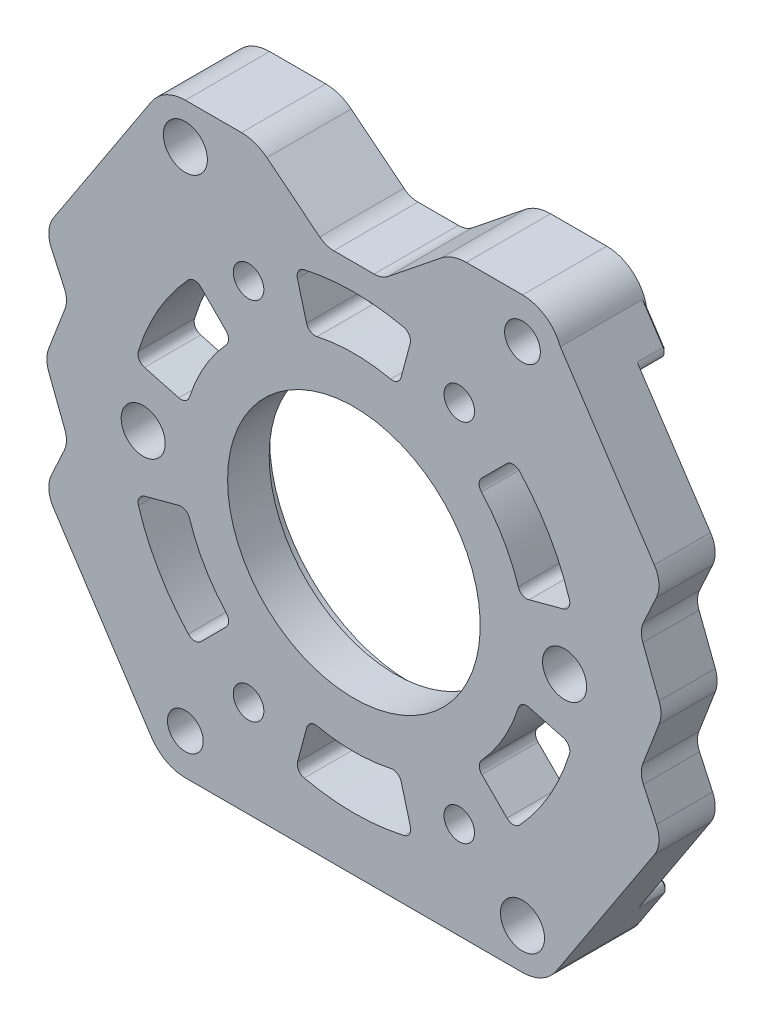
from build123d import *

# Parameters (mm, degrees)
BOSS_EXTRUDE1_DEPTH             = 6.3500000000000005
BOSS_EXTRUDE2_START             = 3.1750000000000025
BOSS_EXTRUDE2_DEPTH             = 3.1750000000000025
BOSS_EXTRUDE3_START             = 3.1749999999999954
BOSS_EXTRUDE3_DEPTH             = 3.1749999999999954
CUT_EXTRUDE1_DEPTH              = 50.09222906010686
CUT_EXTRUDE2_DEPTH              = 49.57616523656433
CUT_EXTRUDE3_DEPTH              = 49.57616523656433
CUT_EXTRUDE4_DEPTH              = 49.57616523656433
CUT_EXTRUDE5_DEPTH              = 49.57616523656433
CUT_EXTRUDE6_DEPTH              = 50.09222906010686
DRAFT1_ANGLE                    = 51.253296654376754
HOLE1_D                         = 4.9784
M3_CLEARANCE_HOLE1_D            = 3.4544
M3_5_CLEARANCE_HOLE1_D          = 4.0386
HOLE2_D                         = 4.9784
CBORE_FOR_M25_SHSS1_D           = 28.5496
CBORE_FOR_M25_SHSS1_CBORE_D     = 31.75
CBORE_FOR_M25_SHSS1_CBORE_DEPTH = 1.651
CHAMFER1_SIZE                   = 0.2500000000000002
FILLET1_R                       = 1.000000000000006
FILLET2_R                       = 2.5400000000000005
FILLET3_R                       = 3.1749999999999967
FILLET4_R                       = 4.584700000000002


with BuildPart() as part:
    # Sketch1 → Boss-Extrude1 (new body)
    with BuildSketch(Plane(origin=(0, 0, -1.5875000000000004), x_dir=(-1, 0, 0), z_dir=(0, 0, -1))):
        with BuildLine():
            Line((-34.925, -12.7), (-21.52807978362314, -33.1597))
            Line((-21.52807978362314, -33.1597), (21.52807978362314, -33.1597))
            Line((21.52807978362314, -33.1597), (34.925, -12.699999999999994))
            Line((34.925, -12.699999999999994), (32.26426055846453, -6.934328692662284))
            Line((32.26426055846453, -6.934328692662284), (34.925000000000004, -8.67e-15))
            Line((34.925000000000004, -8.67e-15), (32.264260558464514, 6.934328692662283))
            Line((32.264260558464514, 6.934328692662283), (34.925, 12.700000000000003))
            Line((34.925, 12.700000000000003), (21.528079783623138, 33.1597))
            Line((21.528079783623138, 33.1597), (-19.049999999999997, 33.159699999999994))
            ThreePointArc((-19.049999999999997, 33.159699999999994), (-21.64706386629015, 32.353191811489985), (-23.330413302302876, 30.217417745723832))
            Line((-23.330413302302876, 30.217417745723832), (-34.925, 12.700000000000008))
            Line((-34.925, 12.700000000000008), (-32.264260558464514, 6.934328692662277))
            Line((-32.264260558464514, 6.934328692662277), (-34.925, -1.908e-14))
            Line((-34.925, -1.908e-14), (-32.26426055846453, -6.934328692662284))
            Line((-32.26426055846453, -6.934328692662284), (-34.925, -12.7))
        make_face()
        with BuildLine():
            Line((-6.64894158563011, -26.205411686227137), (-5.096023285323016, -20.40984168947758))
            ThreePointArc((-5.096023285323016, -20.40984168947758), (-0.01270002424129833, -21.087495864342753), (5.071501613954451, -20.41646362999455))
            Line((5.071501613954451, -20.41646362999455), (6.624416891989551, -26.2120223474715))
            ThreePointArc((6.624416891989551, -26.2120223474715), (-0.01270001417569242, -27.08749683744372), (-6.64894158563011, -26.205411686227137))
        make_face(mode=Mode.SUBTRACT)
    extrude(amount=-BOSS_EXTRUDE1_DEPTH)

    # Sketch2 → Boss-Extrude2 (add)
    with BuildSketch(Plane(origin=(0, 0, -1.5875000000000004), x_dir=(-1, 0, 0), z_dir=(0, 0, -1)).offset(BOSS_EXTRUDE2_START)):
        with BuildLine():
            Line((25.76305455962913, -26.6920707221358), (21.52807978362314, -33.1597))
            Line((21.52807978362314, -33.1597), (-21.528079783623138, -33.1597))
            Line((-21.528079783623138, -33.1597), (-25.76305455962913, -26.6920707221358))
            ThreePointArc((-25.76305455962913, -26.6920707221358), (-25.797274574826115, -25.879824434951267), (-25.09899883749333, -25.463499999999996))
            Line((-25.09899883749333, -25.463499999999996), (-6.450146948450336, -25.463499999999996))
            Line((-6.450146948450336, -25.463499999999996), (-6.64894158563011, -26.205411686227137))
            ThreePointArc((-6.64894158563011, -26.205411686227137), (-0.01270001417569243, -27.087496837443727), (6.624416891989551, -26.2120223474715))
            Line((6.624416891989551, -26.2120223474715), (6.423850933467915, -25.4635))
            Line((6.423850933467915, -25.4635), (25.09899883749333, -25.463499999999996))
            ThreePointArc((25.09899883749333, -25.463499999999996), (25.797274574826115, -25.879824434951267), (25.76305455962913, -26.6920707221358))
        make_face()
    extrude(amount=-BOSS_EXTRUDE2_DEPTH)

    # Sketch3 → Boss-Extrude3 (add)
    with BuildSketch(Plane(origin=(0, 0, -1.5875000000000004), x_dir=(-1, 0, 0), z_dir=(0, 0, -1)).offset(BOSS_EXTRUDE3_START)):
        with BuildLine():
            Line((25.098998837493337, 25.463499999999993), (-24.999734458335656, 25.463499999999993))
            ThreePointArc((-24.999734458335656, 25.463499999999993), (-25.69894193532402, 25.881553358248237), (-25.66163027185943, 26.695351580161123))
            Line((-25.66163027185943, 26.695351580161123), (-23.330413302302876, 30.217417745723832))
            ThreePointArc((-23.330413302302876, 30.217417745723832), (-21.647063866290154, 32.35319181148999), (-19.049999999999997, 33.159699999999994))
            Line((-19.049999999999997, 33.159699999999994), (21.528079783623138, 33.1597))
            Line((21.528079783623138, 33.1597), (25.763054559629136, 26.692070722135792))
            ThreePointArc((25.763054559629136, 26.692070722135792), (25.797274574826123, 25.879824434951264), (25.098998837493337, 25.463499999999993))
        make_face()
    extrude(amount=-BOSS_EXTRUDE3_DEPTH)

    # Sketch4 → Cut-Extrude1 (cut, through all)
    with BuildSketch(Plane.XY.offset(4.7625)):
        Polygon((3.1749999999999985, 33.159699999999994), (-3.1749999999999936, 33.1597), (-3.174999999999997, 26.8097), (3.1750000000000016, 26.8097), align=None)
    extrude(amount=-CUT_EXTRUDE1_DEPTH, mode=Mode.SUBTRACT)

    # Sketch5 → Cut-Extrude2 (cut, through all)
    with BuildSketch(Plane(origin=(0, 0, -1.5875000000000004), x_dir=(-1, 0, 0), z_dir=(0, 0, -1))):
        with BuildLine():
            Line((18.84863770445993, 3.410385221372306), (24.644207701209485, 4.963303521679389))
            ThreePointArc((24.644207701209485, 4.963303521679389), (22.089995064736804, 11.15149988381755), (18.01325346297295, 16.461674487457675))
            Line((18.01325346297295, 16.461674487457675), (13.770610023531155, 12.219031048015777))
            ThreePointArc((13.770610023531155, 12.219031048015777), (16.893841804332837, 8.151499388549963), (18.84863770445993, 3.410385221372306))
        make_face()
    extrude(amount=-CUT_EXTRUDE2_DEPTH, mode=Mode.SUBTRACT)

    # Sketch6 → Cut-Extrude3 (cut, through all)
    with BuildSketch(Plane(origin=(0, 0, -1.5875000000000004), x_dir=(-1, 0, 0), z_dir=(0, 0, -1))):
        with BuildLine():
            Line((-24.63767035496275, 4.98784786001398), (-18.842111637485782, 3.434932581978894))
            ThreePointArc((-18.842111637485782, 3.434932581978894), (-16.881141780091692, 8.173496475792982), (-13.752614419137023, 12.236956468105527))
            Line((-13.752614419137023, 12.236956468105527), (-17.995266115579504, 16.479608164547997))
            ThreePointArc((-17.995266115579504, 16.479608164547997), (-22.077295050561307, 11.173496953626382), (-24.63767035496275, 4.98784786001398))
        make_face()
    extrude(amount=-CUT_EXTRUDE3_DEPTH, mode=Mode.SUBTRACT)

    # Sketch7 → Cut-Extrude4 (cut, through all)
    with BuildSketch(Plane(origin=(0, 0, -1.5875000000000004), x_dir=(-1, 0, 0), z_dir=(0, 0, -1))):
        with BuildLine():
            Line((-18.013253462973076, -19.636674487457547), (-13.770610023531276, -15.394031048015691))
            ThreePointArc((-13.770610023531276, -15.394031048015691), (-16.89384180433294, -11.326499388549841), (-18.848637704460007, -6.585385221372149))
            Line((-18.848637704460007, -6.585385221372149), (-24.64420770120953, -8.13830352167922))
            ThreePointArc((-24.64420770120953, -8.13830352167922), (-22.089995064736897, -14.326499883817393), (-18.013253462973076, -19.636674487457547))
        make_face()
    extrude(amount=-CUT_EXTRUDE4_DEPTH, mode=Mode.SUBTRACT)

    # Sketch8 → Cut-Extrude5 (cut, through all)
    with BuildSketch(Plane(origin=(0, 0, -1.5875000000000004), x_dir=(-1, 0, 0), z_dir=(0, 0, -1))):
        with BuildLine():
            Line((-6.6244168919895525, 23.03702234747152), (-5.071501613954452, 17.241463629994563))
            ThreePointArc((-5.071501613954452, 17.241463629994563), (0.01270002424129464, 17.912495864342766), (5.096023285323016, 17.23484168947759))
            Line((5.096023285323016, 17.23484168947759), (6.648941585630111, 23.030411686227147))
            ThreePointArc((6.648941585630111, 23.030411686227147), (0.01270001417568948, 23.912496837443737), (-6.6244168919895525, 23.03702234747152))
        make_face()
    extrude(amount=-CUT_EXTRUDE5_DEPTH, mode=Mode.SUBTRACT)

    # Sketch9 → Cut-Extrude6 (cut, through all)
    with BuildSketch(Plane.XY.offset(4.7625)):
        with BuildLine():
            Line((-18.84211163748581, -6.60993258197876), (-24.637670354962786, -8.16284786001381))
            ThreePointArc((-24.637670354962786, -8.16284786001381), (-22.07729505056139, -14.348496953626228), (-17.995266115579618, -19.65460816454787))
            Line((-17.995266115579618, -19.65460816454787), (-13.75261441913711, -15.411956468105435))
            ThreePointArc((-13.75261441913711, -15.411956468105435), (-16.881141780091756, -11.348496475792864), (-18.84211163748581, -6.60993258197876))
        make_face()
    extrude(amount=-CUT_EXTRUDE6_DEPTH, mode=Mode.SUBTRACT)

    # Draft1
    draft1_faces = [part.faces().sort_by_distance(p)[0] for p in [
        (-3.174999999999995, 29.984700000000004, 2.62e-15),
        (3.175, 29.984699999999997, 2.59e-15),
    ]]
    draft(draft1_faces, Plane(origin=(-3.174999999999997, 26.8097, -4.762525000000003), x_dir=(0, 0, 1), z_dir=(0, 1, 0)), DRAFT1_ANGLE)

    # Hole1 (through all)
    with Locations(Plane(origin=(0, 0, -4.762500000000003), x_dir=(-1, 0, 0), z_dir=(0, 0, -1))):
        with Locations((-19.05, -28.575), (19.05, 28.575)):
            Hole(HOLE1_D / 2)

    # M3 Clearance Hole1 (through all)
    with Locations(Plane(origin=(0, 0, -1.5875000000000004), x_dir=(-1, 0, 0), z_dir=(0, 0, -1))):
        with Locations((11.90625, 19.034729928), (-11.90625, 19.034729928), (-11.90625, -22.209729928), (11.90625, -22.209729928)):
            Hole(M3_CLEARANCE_HOLE1_D / 2)

    # M3.5 Clearance Hole1 (through all)
    with Locations(Plane(origin=(0, 0, -4.762499999999996), x_dir=(-1, 0, 0), z_dir=(0, 0, -1))):
        with Locations((-19.05, 28.575), (19.05, -28.575)):
            Hole(M3_5_CLEARANCE_HOLE1_D / 2)

    # Hole2 (through all)
    with Locations(Plane(origin=(0, 0, -1.5875000000000004), x_dir=(-1, 0, 0), z_dir=(0, 0, -1))):
        with Locations((23.8125, -1.5875), (-23.8125, -1.5875)):
            Hole(HOLE2_D / 2)

    # CBORE for M25 SHSS1 (through all)
    with Locations(Plane(origin=(0, 0, -1.5875000000000004), x_dir=(-1, 0, 0), z_dir=(0, 0, -1))):
        with Locations((0, -1.5875)):
            CounterBoreHole(CBORE_FOR_M25_SHSS1_D / 2, CBORE_FOR_M25_SHSS1_CBORE_D / 2, CBORE_FOR_M25_SHSS1_CBORE_DEPTH)

    # Chamfer1
    chamfer1_edges = [part.edges().sort_by_distance(p)[0] for p in [
        (-23.645567171626134, -29.9258853610679, -4.762500000000003),
        (-25.797274574826115, -25.879824434951267, -4.762500000000003),
        (-15.761424885480622, -25.463499999999996, -4.762500000000003),
        (24.496021787081155, 28.456384662942476, -4.762499999999996),
        (-23.645567171626137, 29.9258853610679, -4.762499999999996),
        (25.69894193532402, 25.881553358248237, -4.762499999999996),
        (-25.797274574826123, 25.87982443495126, -4.762499999999996),
        (-0.04963218957884052, 25.463499999999993, -4.762499999999996),
        (23.645567171626134, -29.9258853610679, -4.762500000000003),
        (25.797274574826115, -25.879824434951267, -4.762500000000003),
        (15.774572892971833, -25.463499999999996, -4.762500000000003),
    ]]
    chamfer(chamfer1_edges, length=CHAMFER1_SIZE)

    # Fillet1
    fillet1_edges = [part.edges().sort_by_distance(p)[0] for p in [
        (-24.637670354962783, -8.16284786001381, 1.5875),
        (18.842111637485786, 3.434932581978895, 1.5875),
        (5.071501613954451, 17.241463629994563, 1.5875),
        (-5.071501613954452, -20.41646362999455, 1.5875),
        (13.752614419137025, 12.236956468105529, 1.5875),
        (-17.995266115579614, -19.65460816454787, 1.5875),
        (-13.75261441913711, -15.411956468105435, 1.5875),
        (-6.6244168919895525, -26.2120223474715, -8.9e-16),
        (24.63767035496275, 4.987847860013981, 1.5875),
        (6.64894158563011, -26.205411686227137, -1.78e-15),
        (17.995266115579504, 16.479608164547997, 1.5875),
        (-18.013253462972955, 16.461674487457678, 1.5875),
        (6.624416891989553, 23.037022347471524, 1.5875),
        (18.01325346297308, -19.636674487457547, 1.5875),
        (-18.84211163748581, -6.609932581978759, 1.5875),
        (13.770610023531276, -15.394031048015691, 1.5875),
        (5.096023285323016, -20.40984168947758, 1.5875),
        (24.644207701209535, -8.13830352167922, 1.5875),
        (18.84863770446001, -6.5853852213721495, 1.5875),
        (-24.64420770120949, 4.963303521679391, 1.5875),
        (-13.770610023531155, 12.219031048015777, 1.5875),
        (-6.648941585630112, 23.03041168622715, 1.5875),
        (-18.84863770445993, 3.4103852213723083, 1.5875),
        (-5.096023285323016, 17.23484168947759, 1.5875),
    ]]
    fillet(fillet1_edges, radius=FILLET1_R)

    # Fillet2
    fillet2_edges = [part.edges().sort_by_distance(p)[0] for p in [
        (3.1750000000000003, 26.8097, 2.66e-15),
        (-3.1749999999999963, 26.8097, 2.66e-15),
        (32.26426055846453, -6.934328692662284, 1.5875),
        (32.264260558464514, 6.934328692662277, 1.5875),
        (-32.264260558464514, 6.934328692662283, 1.5875),
        (-32.26426055846453, -6.934328692662284, 1.5875),
    ]]
    fillet(fillet2_edges, radius=FILLET2_R)

    # Fillet3
    fillet3_edges = [part.edges().sort_by_distance(p)[0] for p in [
        (-34.925000000000004, -8.67e-15, 1.5875),
        (34.925, 12.700000000000008, 1.5875),
        (34.925, -1.908e-14, 1.5875),
        (-34.925, -12.699999999999994, 1.5875),
        (-34.925, 12.700000000000003, 1.5875),
        (34.925, -12.7, 1.5875),
    ]]
    fillet(fillet3_edges, radius=FILLET3_R)

    # Fillet4
    fillet4_edges = [part.edges().sort_by_distance(p)[0] for p in [
        (11.08786866181818, 33.159699999999994, 1.78e-15),
        (-21.528079783623138, 33.1597, 0.1250000000000009),
        (-11.087868661818181, 33.1597, 1.78e-15),
        (21.52807978362314, -33.1597, 0.12499999999999822),
        (-21.52807978362314, -33.1597, 0.12499999999999822),
    ]]
    fillet(fillet4_edges, radius=FILLET4_R)


solid = part.part
